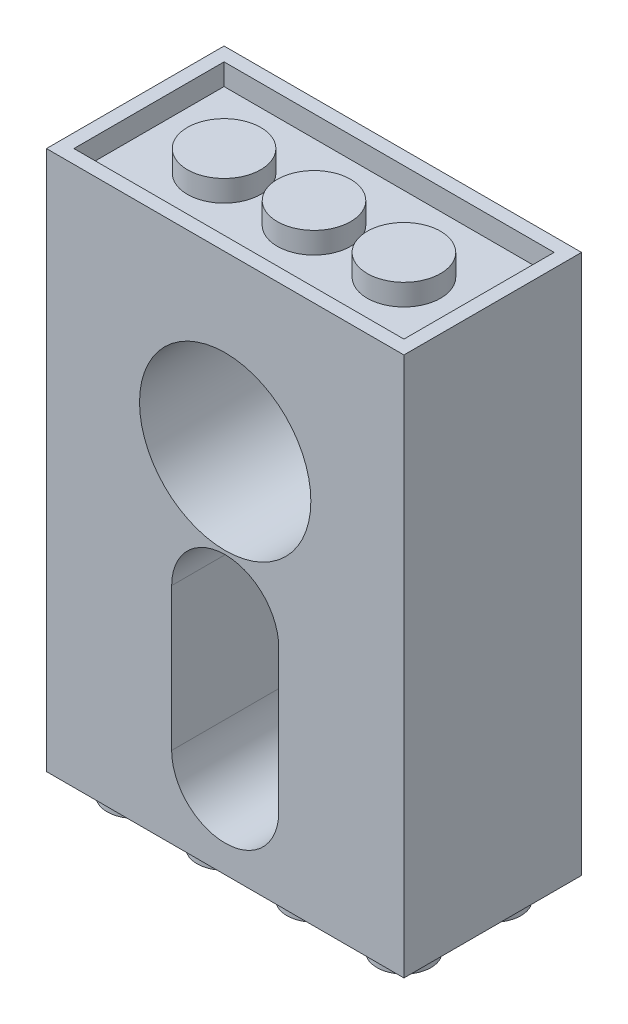
from build123d import *

# Parameters (mm, degrees)
SKETCH1_W           = 31.8
SKETCH1_H           = 48
BOSS_EXTRUDE1_DEPTH = 15.8
SKETCH2_R           = 7.62
CUT_EXTRUDE1_DEPTH  = 12.7
SKETCH3_R           = 2.77815
SKETCH3_R_2         = 1.8415
CUT_EXTRUDE2_DEPTH  = 12.7
CUT_EXTRUDE3_DEPTH  = 1.905
SKETCH5_R           = 2.4
BOSS_EXTRUDE2_DEPTH = 1.905
SKETCH6_W           = 29.36
SKETCH6_H           = 13.36
SKETCH6_R           = 3.2605
CUT_EXTRUDE4_DEPTH  = 1.905


with BuildPart() as part:
    # Sketch1 → Boss-Extrude1 (new body)
    with BuildSketch(Plane.XY):
        Rectangle(SKETCH1_W, SKETCH1_H)
    extrude(amount=BOSS_EXTRUDE1_DEPTH)

    # Sketch2 → Cut-Extrude1 (cut)
    with BuildSketch(Plane.XY.offset(15.8)):
        with Locations((0, 8.6)):
            Circle(SKETCH2_R)
        with BuildLine():
            Line((4.7625, -4.1), (4.7625, -16.8))
            ThreePointArc((4.7625, -16.8), (0, -21.5625), (-4.7625, -16.8))
            Line((-4.7625, -16.8), (-4.7625, -4.1))
            ThreePointArc((-4.7625, -4.1), (0, 0.6625), (4.7625, -4.1))
        make_face()
    extrude(amount=-CUT_EXTRUDE1_DEPTH, mode=Mode.SUBTRACT)

    # Sketch3 → Cut-Extrude2 (cut)
    with BuildSketch(Plane(origin=(0, 0, 0), x_dir=(-1, 0, 0), z_dir=(0, 0, -1))):
        with Locations((0, 8.6)):
            Circle(SKETCH3_R)
        with Locations((0, -4.1)):
            Circle(SKETCH3_R_2)
        with Locations((0, -16.8)):
            Circle(SKETCH3_R_2)
    extrude(amount=-CUT_EXTRUDE2_DEPTH, mode=Mode.SUBTRACT)

    # Sketch4 → Cut-Extrude3 (cut)
    with BuildSketch(Plane(origin=(0, 0, 0), x_dir=(-1, 0, 0), z_dir=(0, 0, -1))):
        with BuildLine():
            Line((4.7625, -16.8), (4.7625, -4.1))
            ThreePointArc((4.7625, -4.1), (0, 0.6625), (-4.7625, -4.1))
            Line((-4.7625, -4.1), (-4.7625, -16.8))
            ThreePointArc((-4.7625, -16.8), (0, -21.5625), (4.7625, -16.8))
        make_face()
    extrude(amount=-CUT_EXTRUDE3_DEPTH, mode=Mode.SUBTRACT)

    # Sketch5 → Boss-Extrude2 (add)
    with BuildSketch(Plane.XZ.offset(24)):
        with Locations((-12, 11.9)):
            Circle(SKETCH5_R)
        with Locations((-12, 3.9)):
            Circle(SKETCH5_R)
        with Locations((-4, 11.9)):
            Circle(SKETCH5_R)
        with Locations((-4, 3.9)):
            Circle(SKETCH5_R)
        with Locations((4, 11.9)):
            Circle(SKETCH5_R)
        with Locations((4, 3.9)):
            Circle(SKETCH5_R)
        with Locations((12, 11.9)):
            Circle(SKETCH5_R)
        with Locations((12, 3.9)):
            Circle(SKETCH5_R)
    extrude(amount=BOSS_EXTRUDE2_DEPTH)

    # Sketch6 → Cut-Extrude4 (cut)
    with BuildSketch(Plane(origin=(0, 24, 0), x_dir=(1, 0, 0), z_dir=(0, 1, 0))):
        with Locations((0, -7.9)):
            Rectangle(SKETCH6_W, SKETCH6_H)
        with Locations((-8, -7.9)):
            Circle(SKETCH6_R, mode=Mode.SUBTRACT)
        with Locations((0, -7.9)):
            Circle(SKETCH6_R, mode=Mode.SUBTRACT)
        with Locations((8, -7.9)):
            Circle(SKETCH6_R, mode=Mode.SUBTRACT)
    extrude(amount=-CUT_EXTRUDE4_DEPTH, mode=Mode.SUBTRACT)


solid = part.part
